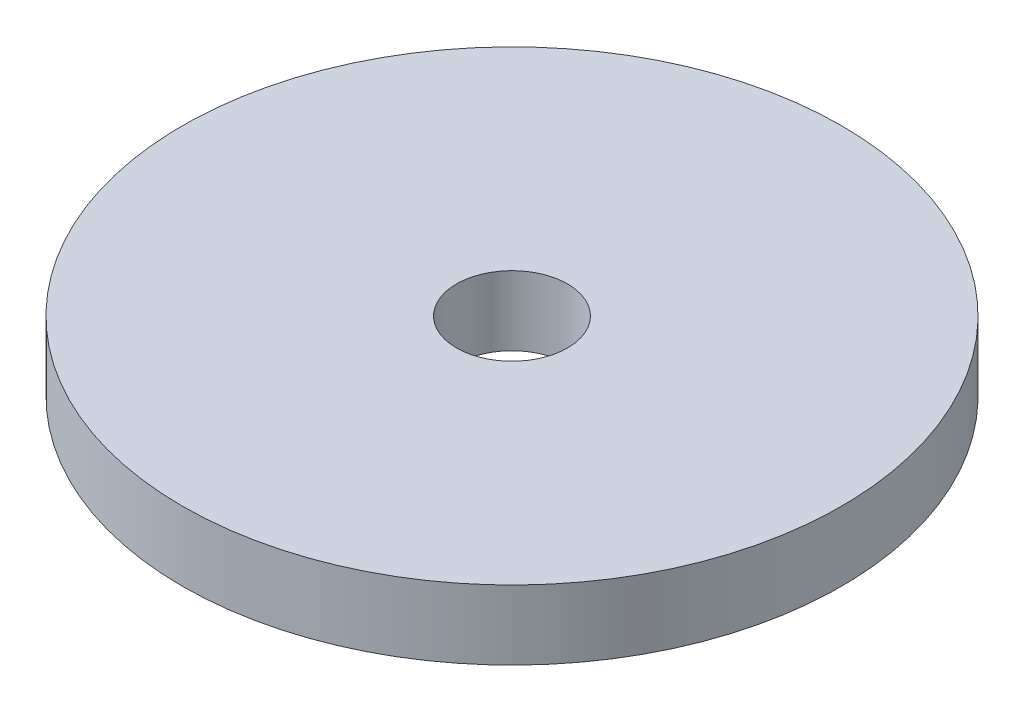
from build123d import *

# Parameters (mm, degrees)
SKETCH1_R           = 12.065
SKETCH1_R_2         = 2.032
BOSS_EXTRUDE1_DEPTH = 2.54


with BuildPart() as part:
    # Sketch1 → Boss-Extrude1 (new body)
    with BuildSketch(Plane(origin=(0, 0, 0), x_dir=(1, 0, 0), z_dir=(0, 1, 0))):
        Circle(SKETCH1_R)
        Circle(SKETCH1_R_2, mode=Mode.SUBTRACT)
    extrude(amount=BOSS_EXTRUDE1_DEPTH)


solid = part.part
